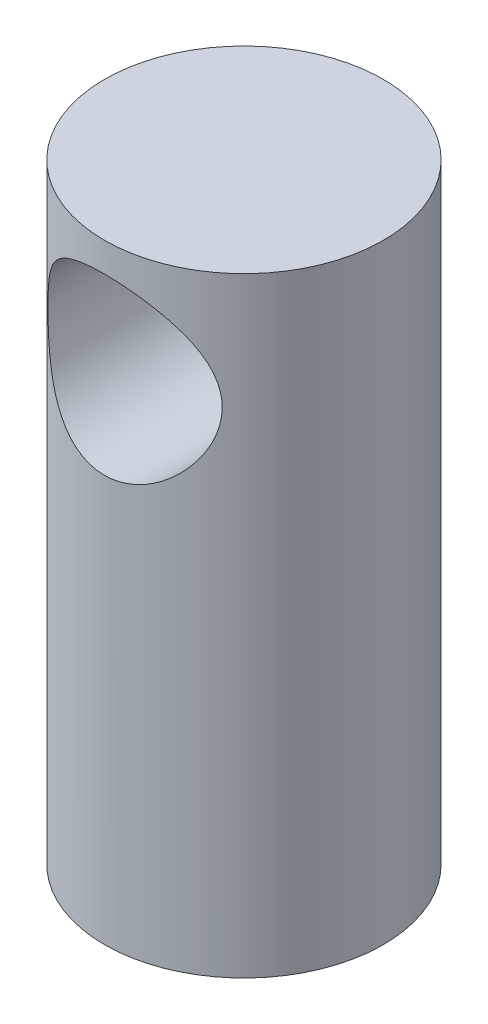
from build123d import *

# Parameters (mm, degrees)
SKETCH1_R               = 8
BOSS_EXTRUDE2_DEPTH     = 35
SKETCH3_R               = 5
CUT_EXTRUDE2_DEPTH      = 9
CUT_EXTRUDE2_DEPTH_BACK = 9


with BuildPart() as part:
    # Sketch1 → Boss-Extrude2 (new body)
    with BuildSketch(Plane(origin=(0, 0, 0), x_dir=(1, 0, 0), z_dir=(0, 1, 0))):
        Circle(SKETCH1_R)
    extrude(amount=BOSS_EXTRUDE2_DEPTH)

    # Sketch3 → Cut-Extrude2 (cut, two sides)
    with BuildSketch(Plane.XY) as cut_extrude2_sk:
        with Locations((0, 28.322111542)):
            Circle(SKETCH3_R)
    extrude(amount=CUT_EXTRUDE2_DEPTH, mode=Mode.SUBTRACT)
    extrude(cut_extrude2_sk.sketch, amount=-CUT_EXTRUDE2_DEPTH_BACK, mode=Mode.SUBTRACT)


solid = part.part
